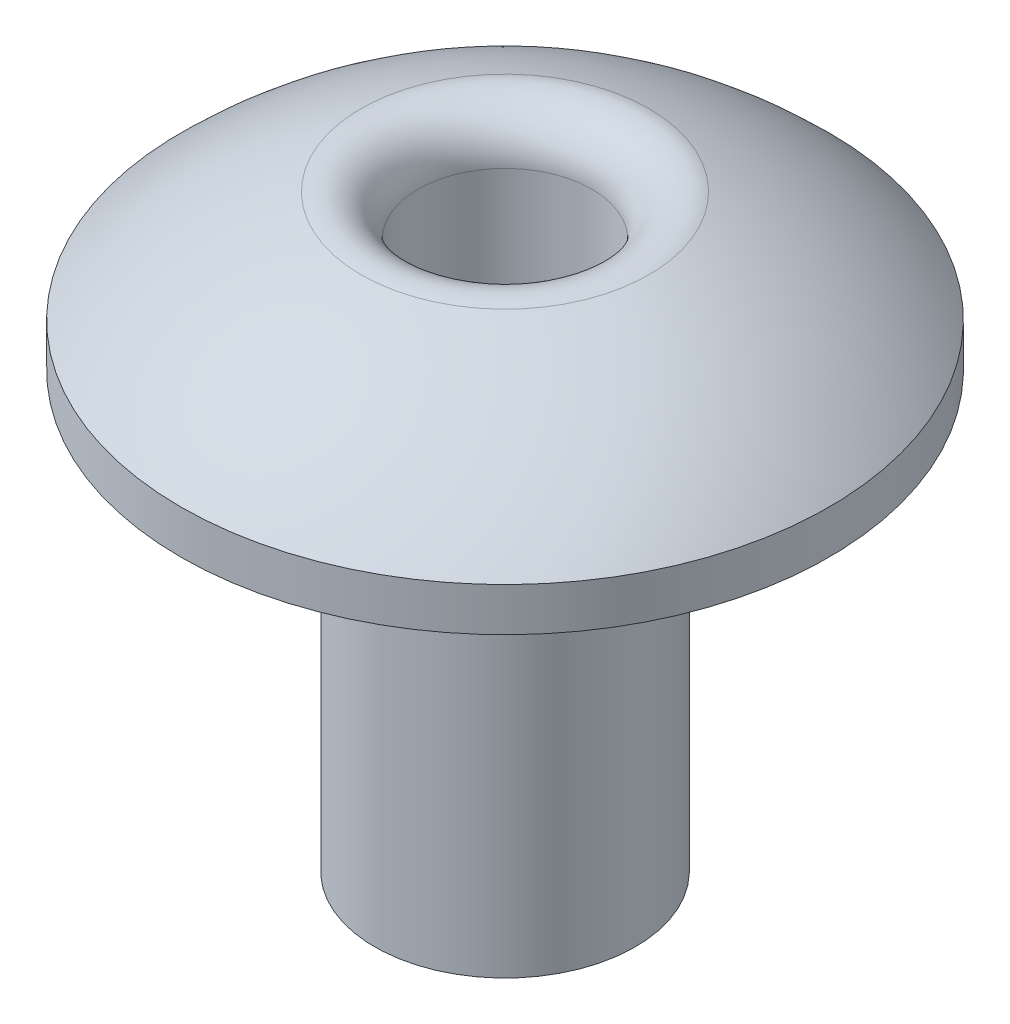
from build123d import *

# Parameters (mm, degrees)
SKETCH3_R           = 1.5
BOSS_EXTRUDE1_DEPTH = 5
SKETCH4_R           = 1
CUT_EXTRUDE1_DEPTH  = 8.04531685
FILLET1_R           = 0.5


with BuildPart() as part:
    # Sketch2 → Revolve2 (revolve)
    with BuildSketch(Plane(origin=(0, 0, 0), x_dir=(0, 0, -1), z_dir=(1, 0, 0))):
        with BuildLine():
            Line((0, 1.54531685), (0, 0))
            Line((0, 0), (0, -0.5))
            Line((0, -0.5), (-3.730724896, -0.5))
            Line((-3.730724896, -0.5), (-3.730724896, 0))
            ThreePointArc((-3.730724896, 0), (-2.019053765, 1.143702085), (0, 1.54531685))
        make_face()
    revolve(axis=Axis((0, -0.5, 0), (0, 1, 0)))

    # Sketch3 → Boss-Extrude1 (add)
    with BuildSketch(Plane.XZ.offset(0.5)):
        Circle(SKETCH3_R)
    extrude(amount=BOSS_EXTRUDE1_DEPTH)

    # Sketch4 → Cut-Extrude1 (cut, through all)
    with BuildSketch(Plane.XZ.offset(5.5)):
        Circle(SKETCH4_R)
    extrude(amount=-CUT_EXTRUDE1_DEPTH, mode=Mode.SUBTRACT)

    # Fillet1
    fillet1_edges = [part.edges().sort_by_distance(p)[0] for p in [
        (-0.707106781, 1.449682086, -0.707106781),
    ]]
    fillet(fillet1_edges, radius=FILLET1_R)


solid = part.part
